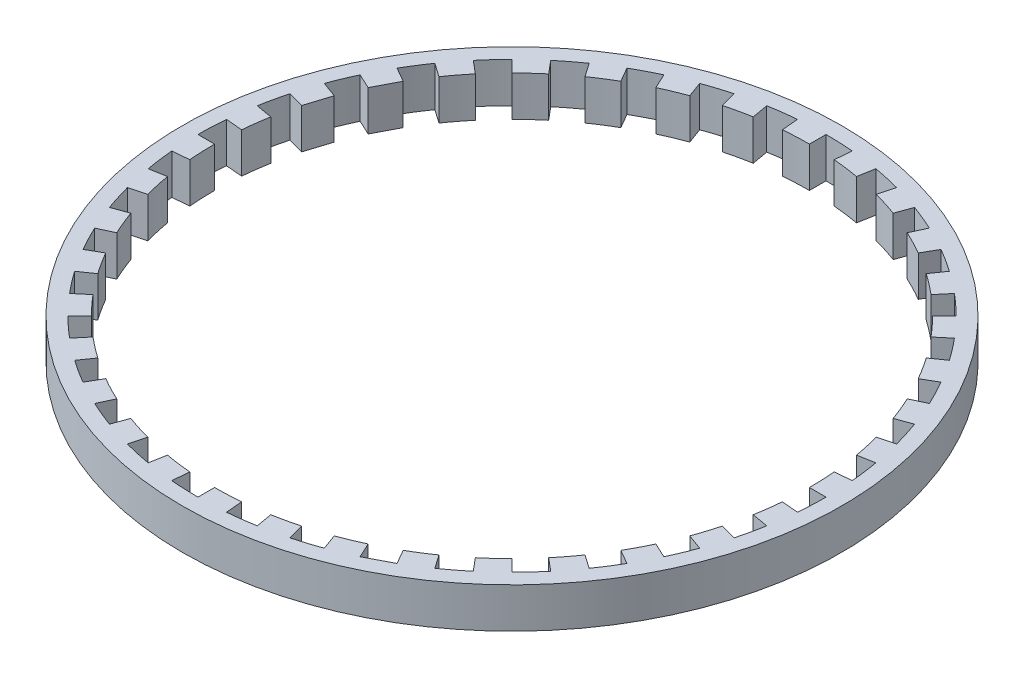
from build123d import *

# Parameters (mm, degrees)
SKETCH_1_R      = 20.5
EXTRUDE_1_DEPTH = 2.5


with BuildPart() as part:
    # 草图1 → 凸台-拉伸1 (new body)
    with BuildSketch(Plane(origin=(0, 0, 0), x_dir=(1, 0, 0), z_dir=(0, 1, 0))):
        Circle(SKETCH_1_R)
        with BuildLine():
            Line((18.5, 0), (19.534629163, 0))
            ThreePointArc((19.534629163, 0), (19.516036524, -0.852088556), (19.460294001, -1.702555114))
            Line((19.460294001, -1.702555114), (18.429601915, -1.612381241))
            ThreePointArc((18.429601915, -1.612381241), (18.341729935, -2.414734556), (18.218943431, -3.212491287))
            Line((18.218943431, -3.212491287), (19.237854252, -3.392152756))
            ThreePointArc((19.237854252, -3.392152756), (19.071580452, -4.228067594), (18.869002815, -5.055934066))
            Line((18.869002815, -5.055934066), (17.869627786, -4.788152334))
            ThreePointArc((17.869627786, -4.788152334), (17.643763589, -5.563057291), (17.384313485, -6.327372652))
            Line((17.384313485, -6.327372652), (18.356546874, -6.681236666))
            ThreePointArc((18.356546874, -6.681236666), (18.047644059, -7.475578938), (17.704386527, -8.255691021))
            Line((17.704386527, -8.255691021), (16.76669406, -7.818437842))
            ThreePointArc((16.76669406, -7.818437842), (16.409700414, -8.542349345), (16.02146997, -9.25))
            Line((16.02146997, -9.25), (16.917485109, -9.767314581))
            ThreePointArc((16.917485109, -9.767314581), (16.475339133, -10.495948598), (16.001831413, -11.204602981))
            Line((16.001831413, -11.204602981), (15.154312819, -10.611164072))
            ThreePointArc((15.154312819, -10.611164072), (14.677036795, -11.262086437), (14.171822198, -11.891570779))
            Line((14.171822198, -11.891570779), (14.964394119, -12.556617586))
            ThreePointArc((14.964394119, -12.556617586), (14.402439365, -13.197404172), (13.813068749, -13.813068749))
            Line((13.813068749, -13.813068749), (13.081475452, -13.081475452))
            ThreePointArc((13.081475452, -13.081475452), (12.498418841, -13.639630731), (11.891570779, -14.171822198))
            Line((11.891570779, -14.171822198), (12.556617586, -14.964394119))
            ThreePointArc((12.556617586, -14.964394119), (11.891928764, -15.497863298), (11.204602981, -16.001831413))
            Line((11.204602981, -16.001831413), (10.611164072, -15.154312819))
            ThreePointArc((10.611164072, -15.154312819), (9.940042754, -15.602741748), (9.25, -16.02146997))
            Line((9.25, -16.02146997), (9.767314581, -16.917485109))
            Line((9.767314581, -16.917485109), (8.255691021, -17.704386527))
            Line((8.255691021, -17.704386527), (7.818437842, -16.76669406))
            ThreePointArc((7.818437842, -16.76669406), (7.079643499, -17.091771351), (6.327372652, -17.384313485))
            Line((6.327372652, -17.384313485), (6.681236666, -18.356546874))
            ThreePointArc((6.681236666, -18.356546874), (5.87417628, -18.630506959), (5.055934066, -18.869002815))
            Line((5.055934066, -18.869002815), (4.788152334, -17.869627786))
            ThreePointArc((4.788152334, -17.869627786), (4.004132858, -18.061476132), (3.212491287, -18.218943431))
            Line((3.212491287, -18.218943431), (3.392152756, -19.237854252))
            ThreePointArc((3.392152756, -19.237854252), (2.549780761, -19.367507702), (1.702555114, -19.460294001))
            Line((1.702555114, -19.460294001), (1.612381241, -18.429601915))
            ThreePointArc((1.612381241, -18.429601915), (0.806958666, -18.482392099), (0, -18.5))
            Line((0, -18.5), (0, -19.534629163))
            ThreePointArc((0, -19.534629163), (-0.852088556, -19.516036524), (-1.702555114, -19.460294001))
            Line((-1.702555114, -19.460294001), (-1.612381241, -18.429601915))
            ThreePointArc((-1.612381241, -18.429601915), (-2.414734556, -18.341729935), (-3.212491287, -18.218943431))
            Line((-3.212491287, -18.218943431), (-3.392152756, -19.237854252))
            ThreePointArc((-3.392152756, -19.237854252), (-4.228067594, -19.071580452), (-5.055934066, -18.869002815))
            Line((-5.055934066, -18.869002815), (-4.788152334, -17.869627786))
            ThreePointArc((-4.788152334, -17.869627786), (-5.563057291, -17.643763589), (-6.327372652, -17.384313485))
            Line((-6.327372652, -17.384313485), (-6.681236666, -18.356546874))
            ThreePointArc((-6.681236666, -18.356546874), (-7.475578938, -18.047644059), (-8.255691021, -17.704386527))
            Line((-8.255691021, -17.704386527), (-7.818437842, -16.76669406))
            ThreePointArc((-7.818437842, -16.76669406), (-8.542349345, -16.409700414), (-9.25, -16.02146997))
            Line((-9.25, -16.02146997), (-9.767314581, -16.917485109))
            ThreePointArc((-9.767314581, -16.917485109), (-10.495948598, -16.475339133), (-11.204602981, -16.001831413))
            Line((-11.204602981, -16.001831413), (-10.611164072, -15.154312819))
            ThreePointArc((-10.611164072, -15.154312819), (-11.262086437, -14.677036795), (-11.891570779, -14.171822198))
            Line((-11.891570779, -14.171822198), (-12.556617586, -14.964394119))
            ThreePointArc((-12.556617586, -14.964394119), (-13.197404172, -14.402439365), (-13.813068749, -13.813068749))
            Line((-13.813068749, -13.813068749), (-13.081475452, -13.081475452))
            ThreePointArc((-13.081475452, -13.081475452), (-13.639630731, -12.498418841), (-14.171822198, -11.891570779))
            Line((-14.171822198, -11.891570779), (-14.964394119, -12.556617586))
            ThreePointArc((-14.964394119, -12.556617586), (-15.497863298, -11.891928764), (-16.001831413, -11.204602981))
            Line((-16.001831413, -11.204602981), (-15.154312819, -10.611164072))
            ThreePointArc((-15.154312819, -10.611164072), (-15.602741748, -9.940042754), (-16.02146997, -9.25))
            Line((-16.02146997, -9.25), (-16.917485109, -9.767314581))
            ThreePointArc((-16.917485109, -9.767314581), (-17.32742769, -9.020087926), (-17.704386527, -8.255691021))
            Line((-17.704386527, -8.255691021), (-16.76669406, -7.818437842))
            ThreePointArc((-16.76669406, -7.818437842), (-17.091771351, -7.079643499), (-17.384313485, -6.327372652))
            Line((-17.384313485, -6.327372652), (-18.356546874, -6.681236666))
            ThreePointArc((-18.356546874, -6.681236666), (-18.630506959, -5.87417628), (-18.869002815, -5.055934066))
            Line((-18.869002815, -5.055934066), (-17.869627786, -4.788152334))
            ThreePointArc((-17.869627786, -4.788152334), (-18.061476132, -4.004132858), (-18.218943431, -3.212491287))
            Line((-18.218943431, -3.212491287), (-19.237854252, -3.392152756))
            ThreePointArc((-19.237854252, -3.392152756), (-19.367507702, -2.549780761), (-19.460294001, -1.702555114))
            Line((-19.460294001, -1.702555114), (-18.429601915, -1.612381241))
            ThreePointArc((-18.429601915, -1.612381241), (-18.482392099, -0.806958666), (-18.5, 0))
            Line((-18.5, 0), (-19.534629163, 0))
            ThreePointArc((-19.534629163, 0), (-19.516036524, 0.852088556), (-19.460294001, 1.702555114))
            Line((-19.460294001, 1.702555114), (-18.429601915, 1.612381241))
            ThreePointArc((-18.429601915, 1.612381241), (-18.341729935, 2.414734556), (-18.218943431, 3.212491287))
            Line((-18.218943431, 3.212491287), (-19.237854252, 3.392152756))
            ThreePointArc((-19.237854252, 3.392152756), (-19.071580452, 4.228067594), (-18.869002815, 5.055934066))
            Line((-18.869002815, 5.055934066), (-17.869627786, 4.788152334))
            Line((-17.869627786, 4.788152334), (-17.384313485, 6.327372652))
            Line((-17.384313485, 6.327372652), (-18.356546874, 6.681236666))
            ThreePointArc((-18.356546874, 6.681236666), (-18.047644059, 7.475578938), (-17.704386527, 8.255691021))
            Line((-17.704386527, 8.255691021), (-16.76669406, 7.818437842))
            Line((-16.76669406, 7.818437842), (-16.02146997, 9.25))
            Line((-16.02146997, 9.25), (-16.917485109, 9.767314581))
            ThreePointArc((-16.917485109, 9.767314581), (-16.475339133, 10.495948598), (-16.001831413, 11.204602981))
            Line((-16.001831413, 11.204602981), (-15.154312819, 10.611164072))
            ThreePointArc((-15.154312819, 10.611164072), (-14.677036795, 11.262086437), (-14.171822198, 11.891570779))
            Line((-14.171822198, 11.891570779), (-14.964394119, 12.556617586))
            ThreePointArc((-14.964394119, 12.556617586), (-14.402439365, 13.197404172), (-13.813068749, 13.813068749))
            Line((-13.813068749, 13.813068749), (-13.081475452, 13.081475452))
            ThreePointArc((-13.081475452, 13.081475452), (-12.498418841, 13.639630731), (-11.891570779, 14.171822198))
            Line((-11.891570779, 14.171822198), (-12.556617586, 14.964394119))
            ThreePointArc((-12.556617586, 14.964394119), (-11.891928764, 15.497863298), (-11.204602981, 16.001831413))
            Line((-11.204602981, 16.001831413), (-10.611164072, 15.154312819))
            ThreePointArc((-10.611164072, 15.154312819), (-9.940042754, 15.602741748), (-9.25, 16.02146997))
            Line((-9.25, 16.02146997), (-9.767314581, 16.917485109))
            ThreePointArc((-9.767314581, 16.917485109), (-9.020087926, 17.32742769), (-8.255691021, 17.704386527))
            Line((-8.255691021, 17.704386527), (-7.818437842, 16.76669406))
            ThreePointArc((-7.818437842, 16.76669406), (-7.079643499, 17.091771351), (-6.327372652, 17.384313485))
            Line((-6.327372652, 17.384313485), (-6.681236666, 18.356546874))
            ThreePointArc((-6.681236666, 18.356546874), (-5.87417628, 18.630506959), (-5.055934066, 18.869002815))
            Line((-5.055934066, 18.869002815), (-4.788152334, 17.869627786))
            ThreePointArc((-4.788152334, 17.869627786), (-4.004132858, 18.061476132), (-3.212491287, 18.218943431))
            Line((-3.212491287, 18.218943431), (-3.392152756, 19.237854252))
            ThreePointArc((-3.392152756, 19.237854252), (-2.549780761, 19.367507702), (-1.702555114, 19.460294001))
            Line((-1.702555114, 19.460294001), (-1.612381241, 18.429601915))
            ThreePointArc((-1.612381241, 18.429601915), (-0.806958666, 18.482392099), (0, 18.5))
            Line((0, 18.5), (0, 19.534629163))
            ThreePointArc((0, 19.534629163), (0.852088556, 19.516036524), (1.702555114, 19.460294001))
            Line((1.702555114, 19.460294001), (1.612381241, 18.429601915))
            ThreePointArc((1.612381241, 18.429601915), (2.414734556, 18.341729935), (3.212491287, 18.218943431))
            Line((3.212491287, 18.218943431), (3.392152756, 19.237854252))
            ThreePointArc((3.392152756, 19.237854252), (4.228067594, 19.071580452), (5.055934066, 18.869002815))
            Line((5.055934066, 18.869002815), (4.788152334, 17.869627786))
            ThreePointArc((4.788152334, 17.869627786), (5.563057291, 17.643763589), (6.327372652, 17.384313485))
            Line((6.327372652, 17.384313485), (6.681236666, 18.356546874))
            ThreePointArc((6.681236666, 18.356546874), (7.475578938, 18.047644059), (8.255691021, 17.704386527))
            Line((8.255691021, 17.704386527), (7.818437842, 16.76669406))
            ThreePointArc((7.818437842, 16.76669406), (8.542349345, 16.409700414), (9.25, 16.02146997))
            Line((9.25, 16.02146997), (9.767314581, 16.917485109))
            ThreePointArc((9.767314581, 16.917485109), (10.495948598, 16.475339133), (11.204602981, 16.001831413))
            Line((11.204602981, 16.001831413), (10.611164072, 15.154312819))
            ThreePointArc((10.611164072, 15.154312819), (11.262086437, 14.677036795), (11.891570779, 14.171822198))
            Line((11.891570779, 14.171822198), (12.556617586, 14.964394119))
            ThreePointArc((12.556617586, 14.964394119), (13.197404172, 14.402439365), (13.813068749, 13.813068749))
            Line((13.813068749, 13.813068749), (13.081475452, 13.081475452))
            ThreePointArc((13.081475452, 13.081475452), (13.639630731, 12.498418841), (14.171822198, 11.891570779))
            Line((14.171822198, 11.891570779), (14.964394119, 12.556617586))
            ThreePointArc((14.964394119, 12.556617586), (15.497863298, 11.891928764), (16.001831413, 11.204602981))
            Line((16.001831413, 11.204602981), (15.154312819, 10.611164072))
            ThreePointArc((15.154312819, 10.611164072), (15.602741748, 9.940042754), (16.02146997, 9.25))
            Line((16.02146997, 9.25), (16.917485109, 9.767314581))
            ThreePointArc((16.917485109, 9.767314581), (17.32742769, 9.020087926), (17.704386527, 8.255691021))
            Line((17.704386527, 8.255691021), (16.76669406, 7.818437842))
            ThreePointArc((16.76669406, 7.818437842), (17.091771351, 7.079643499), (17.384313485, 6.327372652))
            Line((17.384313485, 6.327372652), (18.356546874, 6.681236666))
            ThreePointArc((18.356546874, 6.681236666), (18.630506959, 5.87417628), (18.869002815, 5.055934066))
            Line((18.869002815, 5.055934066), (17.869627786, 4.788152334))
            ThreePointArc((17.869627786, 4.788152334), (18.061476132, 4.004132858), (18.218943431, 3.212491287))
            Line((18.218943431, 3.212491287), (19.237854252, 3.392152756))
            ThreePointArc((19.237854252, 3.392152756), (19.367507702, 2.549780761), (19.460294001, 1.702555114))
            Line((19.460294001, 1.702555114), (18.429601915, 1.612381241))
            ThreePointArc((18.429601915, 1.612381241), (18.482392099, 0.806958666), (18.5, 0))
        make_face(mode=Mode.SUBTRACT)
    extrude(amount=EXTRUDE_1_DEPTH)


solid = part.part
